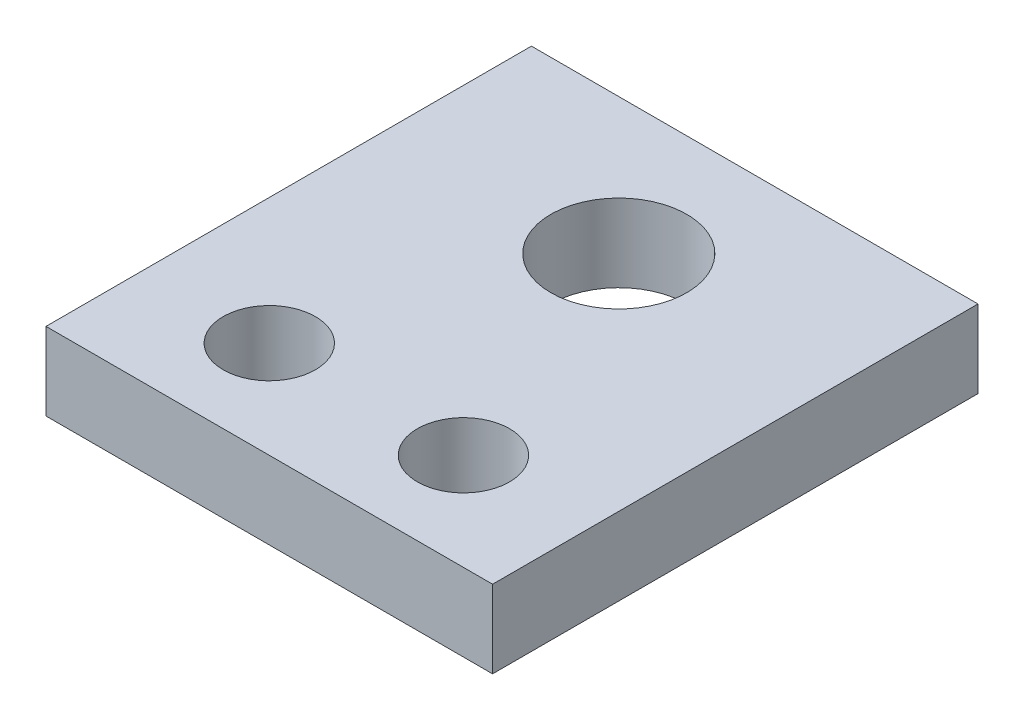
from build123d import *

# Parameters (mm, degrees)
SKETCH_1_W          = 46
SKETCH_1_H          = 50
EXTRUDE_1_DEPTH     = 8
SKETCH_2_R          = 7
SKETCH_2_R_2        = 4.75
CUT_EXTRUDE_1_DEPTH = 8


with BuildPart() as part:
    # 草图1 → 凸台-拉伸1 (new body)
    with BuildSketch(Plane(origin=(0, 0, 0), x_dir=(1, 0, 0), z_dir=(0, 1, 0))):
        Rectangle(SKETCH_1_W, SKETCH_1_H)
    extrude(amount=EXTRUDE_1_DEPTH)

    # 草图2 → 切除-拉伸1 (cut)
    with BuildSketch(Plane(origin=(0, 8, 0), x_dir=(1, 0, 0), z_dir=(0, 1, 0))):
        with Locations((0, 11)):
            Circle(SKETCH_2_R)
        with Locations((-10, -15)):
            Circle(SKETCH_2_R_2)
        with Locations((10, -15)):
            Circle(SKETCH_2_R_2)
    extrude(amount=-CUT_EXTRUDE_1_DEPTH, mode=Mode.SUBTRACT)


solid = part.part
